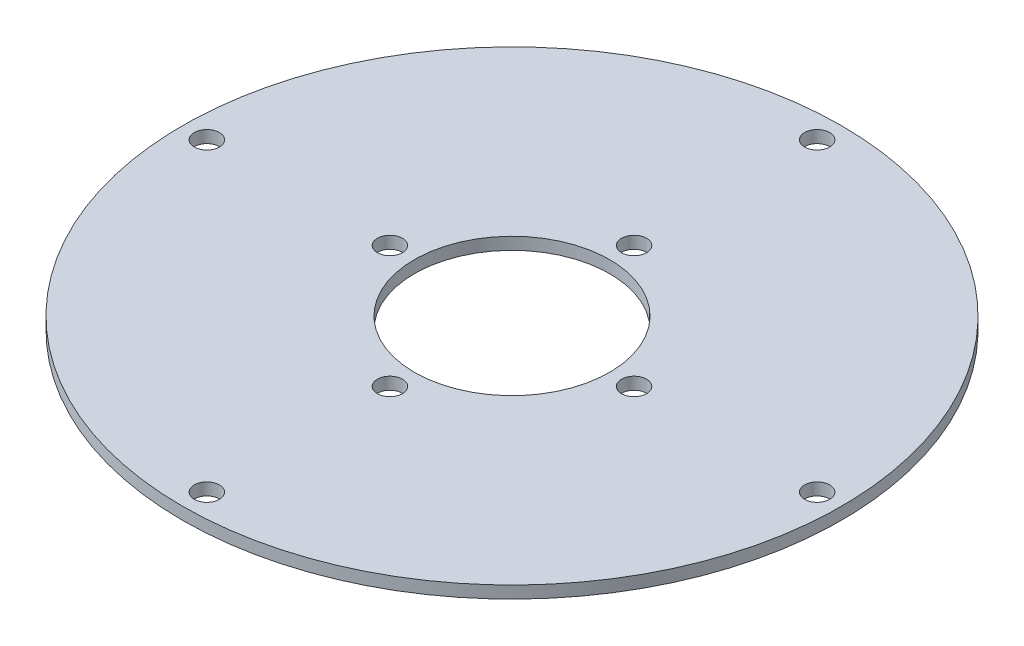
from build123d import *

# Parameters (mm, degrees)
SKETCH1_R           = 85.725
SKETCH1_R_2         = 25.4
SKETCH1_R_3         = 3.2639
BOSS_EXTRUDE1_DEPTH = 3.175


with BuildPart() as part:
    # Sketch1 → Boss-Extrude1 (new body)
    with BuildSketch(Plane(origin=(0, 0, 0), x_dir=(1, 0, 0), z_dir=(0, 1, 0))):
        Circle(SKETCH1_R)
        Circle(SKETCH1_R_2, mode=Mode.SUBTRACT)
        with Locations((0, 79.375)):
            Circle(SKETCH1_R_3, mode=Mode.SUBTRACT)
        with Locations((79.375, 0)):
            Circle(SKETCH1_R_3, mode=Mode.SUBTRACT)
        with Locations((0, -79.375)):
            Circle(SKETCH1_R_3, mode=Mode.SUBTRACT)
        with Locations((-79.375, 0)):
            Circle(SKETCH1_R_3, mode=Mode.SUBTRACT)
        with Locations((0, 31.75)):
            Circle(SKETCH1_R_3, mode=Mode.SUBTRACT)
        with Locations((31.75, 0)):
            Circle(SKETCH1_R_3, mode=Mode.SUBTRACT)
        with Locations((0, -31.75)):
            Circle(SKETCH1_R_3, mode=Mode.SUBTRACT)
        with Locations((-31.75, 0)):
            Circle(SKETCH1_R_3, mode=Mode.SUBTRACT)
    extrude(amount=BOSS_EXTRUDE1_DEPTH)


solid = part.part
